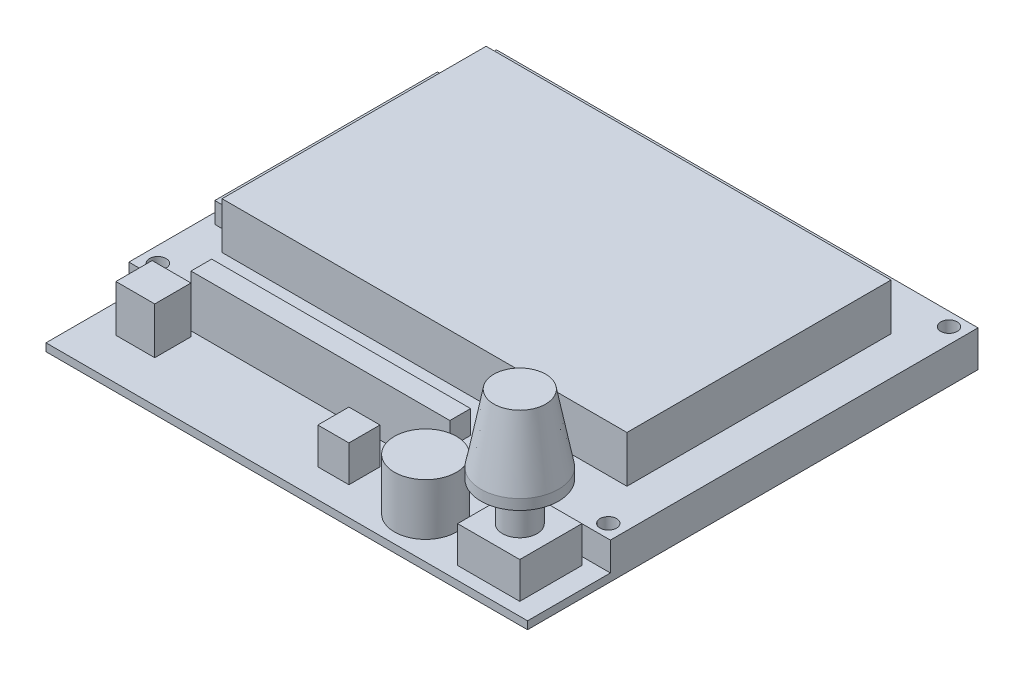
from build123d import *

# Parameters (mm, degrees)
SKETCH_1_W          = 93
SKETCH_1_H          = 87
SKETCH_1_R          = 1.6
EXTRUDE_1_DEPTH     = 7
SKETCH_3_W          = 93
SKETCH_3_H          = 16
CUT_EXTRUDE_1_DEPTH = 5.5
SKETCH_4_W          = 78.2
SKETCH_4_H          = 51
EXTRUDE_2_DEPTH     = 9
SKETCH_5_W          = 12
SKETCH_5_H          = 12
EXTRUDE_3_DEPTH     = 7
SKETCH_6_R          = 3.35
EXTRUDE_4_DEPTH     = 7.5
SKETCH1_W           = 5.4
SKETCH1_H           = 43
BOSS_EXTRUDE1_DEPTH = 4
SKETCH2_R           = 6
BOSS_EXTRUDE2_DEPTH = 10
SKETCH3_W           = 50
SKETCH3_H           = 4
BOSS_EXTRUDE3_DEPTH = 4.5
SKETCH4_W           = 7.5
SKETCH4_H           = 7
BOSS_EXTRUDE4_DEPTH = 9
SKETCH5_W           = 6
SKETCH5_H           = 6
BOSS_EXTRUDE5_DEPTH = 7


with BuildPart() as part:
    # Эскиз1 → Бобышка-Вытянуть1 (new body)
    with BuildSketch(Plane(origin=(0, 0, 0), x_dir=(1, 0, 0), z_dir=(0, 1, 0))):
        with Locations((46.5, 43.5)):
            Rectangle(SKETCH_1_W, SKETCH_1_H)
        with Locations((3, 84.4)):
            Circle(SKETCH_1_R, mode=Mode.SUBTRACT)
        with Locations((90, 84.4)):
            Circle(SKETCH_1_R, mode=Mode.SUBTRACT)
        with Locations((90, 18.6)):
            Circle(SKETCH_1_R, mode=Mode.SUBTRACT)
        with Locations((3, 18.6)):
            Circle(SKETCH_1_R, mode=Mode.SUBTRACT)
    extrude(amount=EXTRUDE_1_DEPTH)

    # Эскиз3 → Вырез-Вытянуть1 (cut)
    with BuildSketch(Plane(origin=(0, 7, 0), x_dir=(1, 0, 0), z_dir=(0, 1, 0))):
        with Locations((46.5, 8)):
            Rectangle(SKETCH_3_W, SKETCH_3_H)
    extrude(amount=-CUT_EXTRUDE_1_DEPTH, mode=Mode.SUBTRACT)

    # Эскиз4 → Бобышка-Вытянуть2 (add)
    with BuildSketch(Plane(origin=(0, 7, 0), x_dir=(1, 0, 0), z_dir=(0, 1, 0))):
        with Locations((46.5, 52.1)):
            Rectangle(SKETCH_4_W, SKETCH_4_H)
    extrude(amount=EXTRUDE_2_DEPTH)

    # Эскиз5 → Бобышка-Вытянуть3 (add)
    with BuildSketch(Plane(origin=(0, 1.5, 0), x_dir=(1, 0, 0), z_dir=(0, 1, 0))):
        with Locations((83, 8.5)):
            Rectangle(SKETCH_5_W, SKETCH_5_H)
    extrude(amount=EXTRUDE_3_DEPTH)

    # Эскиз6 → Бобышка-Вытянуть4 (add)
    with BuildSketch(Plane(origin=(0, 8.5, 0), x_dir=(1, 0, 0), z_dir=(0, 1, 0))):
        with Locations((83, 8.5)):
            Circle(SKETCH_6_R)
    extrude(amount=EXTRUDE_4_DEPTH)

    # Sketch1 → Boss-Extrude1 (add)
    with BuildSketch(Plane(origin=(0, 7, 0), x_dir=(1, 0, 0), z_dir=(0, 1, 0))):
        with Locations((4.7, 52.1)):
            Rectangle(SKETCH1_W, SKETCH1_H)
    extrude(amount=BOSS_EXTRUDE1_DEPTH)

    # Эскиз9 → Revolve1 (revolve)
    with BuildSketch(Plane.ZY.offset(-83)):
        Polygon((-8.5, 16), (-16, 16), (-16, 18), (-13.5, 31), (-8.5, 31), align=None)
    revolve(axis=Axis((83, 16, -8.5), (0, 1, 0)))

    # Sketch2 → Boss-Extrude2 (add)
    with BuildSketch(Plane(origin=(0, 1.5, 0), x_dir=(1, 0, 0), z_dir=(0, 1, 0))):
        with Locations((65.3, 8)):
            Circle(SKETCH2_R)
    extrude(amount=BOSS_EXTRUDE2_DEPTH)

    # Sketch3 → Boss-Extrude3 (add)
    with BuildSketch(Plane(origin=(0, 7, 0), x_dir=(1, 0, 0), z_dir=(0, 1, 0))):
        with Locations((37, 18)):
            Rectangle(SKETCH3_W, SKETCH3_H)
    extrude(amount=BOSS_EXTRUDE3_DEPTH)

    # Sketch4 → Boss-Extrude4 (add)
    with BuildSketch(Plane(origin=(0, 1.5, 0), x_dir=(1, 0, 0), z_dir=(0, 1, 0))):
        with Locations((9.25, 11.5)):
            Rectangle(SKETCH4_W, SKETCH4_H)
    extrude(amount=BOSS_EXTRUDE4_DEPTH)

    # Sketch5 → Boss-Extrude5 (add)
    with BuildSketch(Plane(origin=(0, 1.5, 0), x_dir=(1, 0, 0), z_dir=(0, 1, 0))):
        with Locations((50, 8.5)):
            Rectangle(SKETCH5_W, SKETCH5_H)
    extrude(amount=BOSS_EXTRUDE5_DEPTH)


solid = part.part
